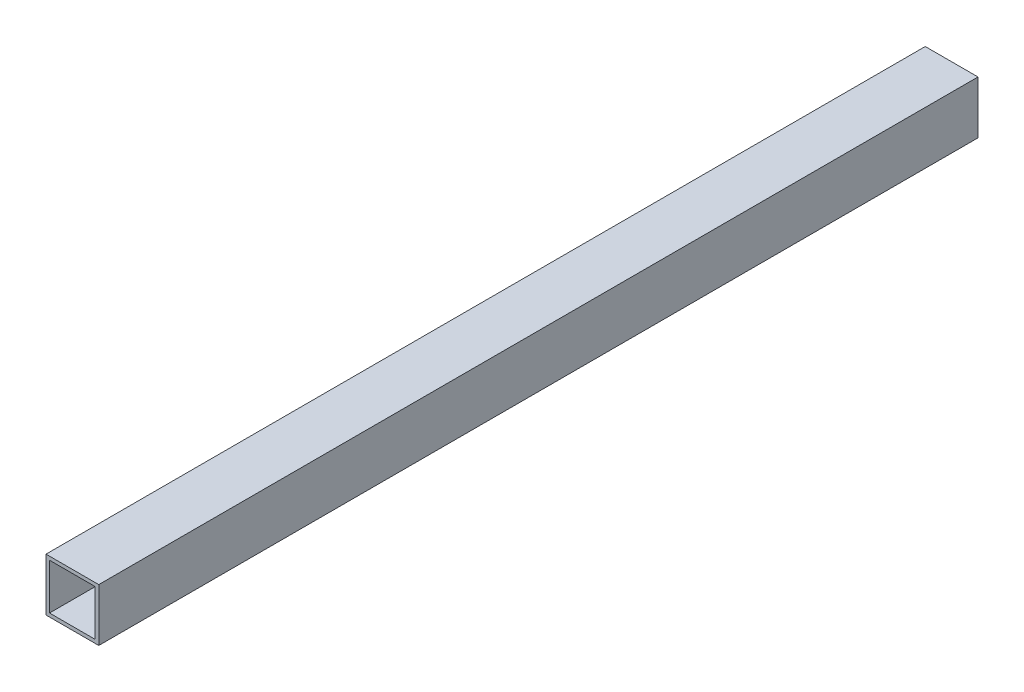
from build123d import *

# Parameters (mm, degrees)
SKETCH1_W   = 60
SKETCH1_H   = 60
SKETCH1_W_2 = 52
SKETCH1_H_2 = 52


with BuildPart() as part:
    # Sweep1: sweep along a curve in space
    with BuildLine() as sweep1_path:
        add(Edge.make_bspline(
            [(0, 0, 0), (0, 0, 1000)],
            knots=[0, 0, 1, 1], degree=1))
    # Sketch1 → Sweep1 (sweep)
    with BuildSketch(Plane.XY):
        Rectangle(SKETCH1_W, SKETCH1_H)
        Rectangle(SKETCH1_W_2, SKETCH1_H_2, mode=Mode.SUBTRACT)
    sweep(path=sweep1_path.line)


solid = part.part
